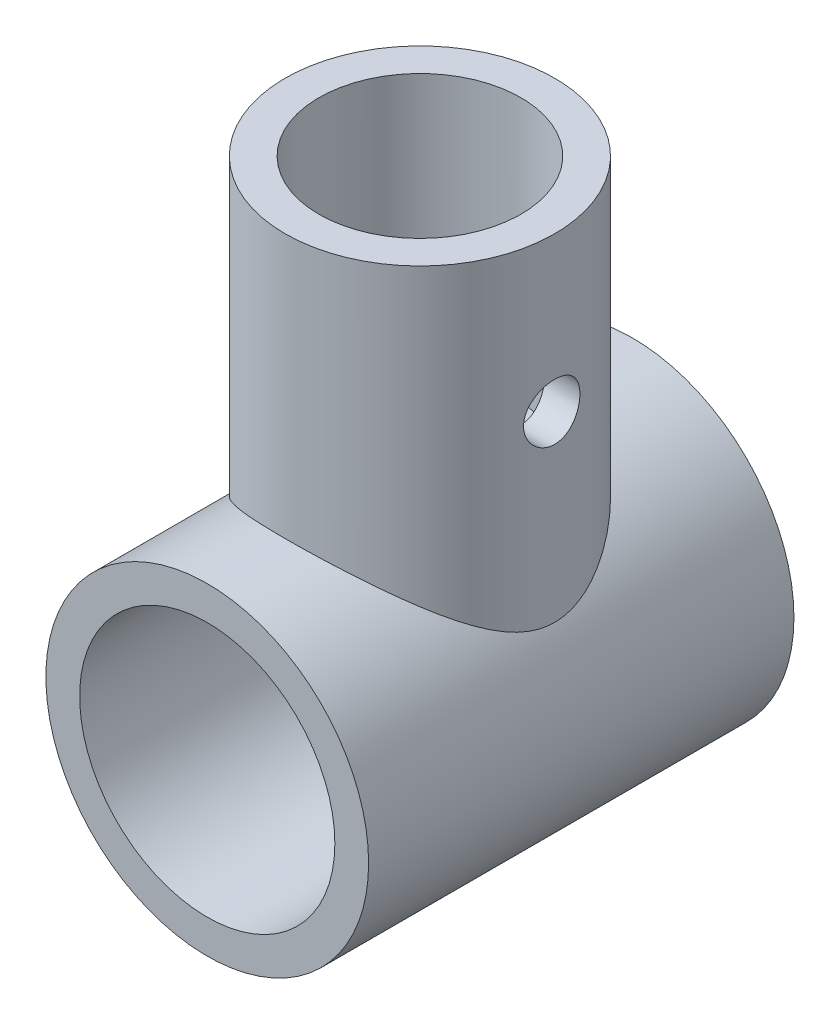
from build123d import *

# Parameters (mm, degrees)
SKETCH1_R           = 15.175
SKETCH1_R_2         = 12
BOSS_EXTRUDE1_DEPTH = 20
BOSS_EXTRUDE2_REACH = 57.175
SKETCH2_R           = 12.675
SKETCH2_R_2         = 9.5
SKETCH5_W           = 2.65
SKETCH5_H           = 15.175


with BuildPart() as part:
    # Sketch1 → Boss-Extrude1 (new body, symmetric)
    with BuildSketch(Plane.XY):
        Circle(SKETCH1_R)
        Circle(SKETCH1_R_2, mode=Mode.SUBTRACT)
    extrude(amount=BOSS_EXTRUDE1_DEPTH, both=True)

    # Sketch2 → Boss-Extrude2 (add, up to next)
    with BuildSketch(Plane(origin=(0, 40, 0), x_dir=(1, 0, 0), z_dir=(0, 1, 0)), mode=Mode.PRIVATE) as boss_extrude2_sk1:
        Circle(SKETCH2_R)
        Circle(SKETCH2_R_2, mode=Mode.SUBTRACT)
    boss_extrude2_tool1 = extrude(boss_extrude2_sk1.sketch, amount=-BOSS_EXTRUDE2_REACH, mode=Mode.PRIVATE) - part.part
    add(boss_extrude2_tool1.solids().sort_by_distance((-12.316497, 40, 0))[0])

    # Sketch5 → M5 Clearance Hole1 (revolve, cut)
    with BuildSketch(Plane.ZX.offset(25.5)):
        with Locations((1.325, 7.5875)):
            Rectangle(SKETCH5_W, SKETCH5_H)
    m5_clearance_hole1 = revolve(axis=Axis((-6.35, 25.5, 0), (1, 0, 0)), mode=Mode.SUBTRACT)

    # Mirror1: M5 Clearance Hole1 across plane
    add(m5_clearance_hole1.mirror(Plane(origin=(0, 0, 0), x_dir=(0, 0, 1), z_dir=(1, 0, 0))), mode=Mode.SUBTRACT)


solid = part.part
